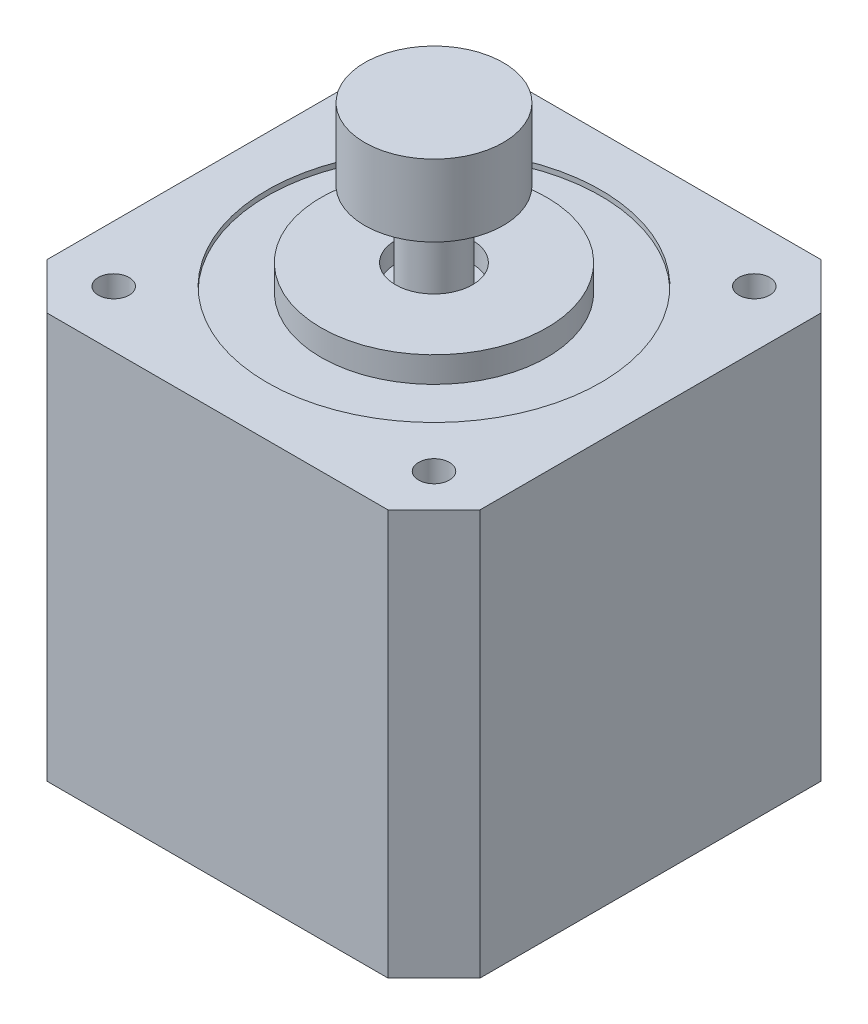
from build123d import *

# Parameters (mm, degrees)
SALIENTE_EXTRUIR1_DEPTH = 39.5
CROQUIS2_R              = 11
CROQUIS2_R_2            = 3.75
SALIENTE_EXTRUIR2_DEPTH = 2
CROQUIS3_R              = 16.25
CROQUIS3_R_2            = 11
CORTAR_EXTRUIR2_DEPTH   = 0.5
CROQUIS4_R              = 2.75
EJE_DEPTH               = 42.5
CROQUIS5_R              = 3.5
PERNOSATRAS_DEPTH       = 2
CROQUIS6_R              = 1.5
PERNOSFRENTE_DEPTH      = 5
CROQUIS7_R              = 2.75
SALIENTE_EXTRUIR3_DEPTH = 55
CROQUIS8_R              = 6.75
SALIENTE_EXTRUIR4_DEPTH = 7


with BuildPart() as part:
    # Croquis1 → Saliente-Extruir1 (new body)
    with BuildSketch(Plane(origin=(0, 0, 0), x_dir=(1, 0, 0), z_dir=(0, 1, 0))):
        Polygon((-16.6, 21.1), (-21.1, 16.6), (-21.1, -16.6), (-16.6, -21.1), (16.6, -21.1), (21.1, -16.6), (21.1, 16.6), (16.6, 21.1), align=None)
    extrude(amount=SALIENTE_EXTRUIR1_DEPTH)

    # Croquis2 → Saliente-Extruir2 (add)
    with BuildSketch(Plane(origin=(0, 39.5, 0), x_dir=(1, 0, 0), z_dir=(0, 1, 0))):
        Circle(CROQUIS2_R)
        Circle(CROQUIS2_R_2, mode=Mode.SUBTRACT)
    extrude(amount=SALIENTE_EXTRUIR2_DEPTH)

    # Croquis3 → Cortar-Extruir2 (cut)
    with BuildSketch(Plane(origin=(0, 39.5, 0), x_dir=(1, 0, 0), z_dir=(0, 1, 0))):
        Circle(CROQUIS3_R)
        Circle(CROQUIS3_R_2, mode=Mode.SUBTRACT)
    extrude(amount=-CORTAR_EXTRUIR2_DEPTH, mode=Mode.SUBTRACT)

    # Croquis4 → EJE (cut, through all)
    with BuildSketch(Plane(origin=(0, 41.5, 0), x_dir=(1, 0, 0), z_dir=(0, 1, 0))):
        Circle(CROQUIS4_R)
    extrude(amount=-EJE_DEPTH, mode=Mode.SUBTRACT)

    # Croquis5 → PernosAtras (cut)
    with BuildSketch(Plane.XZ):
        with Locations((-15.6, 15.6)):
            Circle(CROQUIS5_R)
        with Locations((15.6, 15.6)):
            Circle(CROQUIS5_R)
        with Locations((15.6, -15.6)):
            Circle(CROQUIS5_R)
        with Locations((-15.6, -15.6)):
            Circle(CROQUIS5_R)
    extrude(amount=-PERNOSATRAS_DEPTH, mode=Mode.SUBTRACT)

    # Croquis6 → PernosFrente (cut)
    with BuildSketch(Plane(origin=(0, 39.5, 0), x_dir=(1, 0, 0), z_dir=(0, 1, 0))):
        with Locations((-15.6, 15.6)):
            Circle(CROQUIS6_R)
        with Locations((15.6, 15.6)):
            Circle(CROQUIS6_R)
        with Locations((15.6, -15.6)):
            Circle(CROQUIS6_R)
        with Locations((-15.6, -15.6)):
            Circle(CROQUIS6_R)
    extrude(amount=-PERNOSFRENTE_DEPTH, mode=Mode.SUBTRACT)

    # Croquis7 → Saliente-Extruir3 (add)
    with BuildSketch(Plane.XZ):
        Circle(CROQUIS7_R)
    extrude(amount=-SALIENTE_EXTRUIR3_DEPTH)

    # Croquis8 → Saliente-Extruir4 (add)
    with BuildSketch(Plane(origin=(0, 55, 0), x_dir=(1, 0, 0), z_dir=(0, 1, 0))):
        Circle(CROQUIS8_R)
    extrude(amount=-SALIENTE_EXTRUIR4_DEPTH)


solid = part.part
